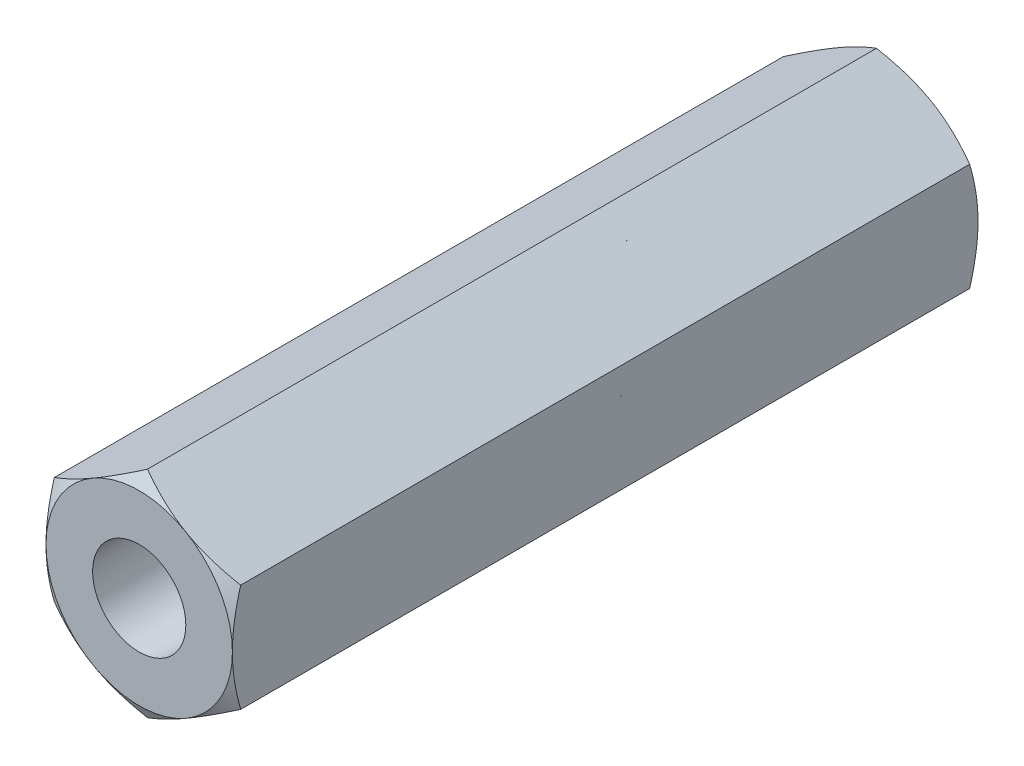
from build123d import *

# Parameters (mm, degrees)
EXTRUDE1_DEPTH          = 20
EXTRUDE1_DEPTH_BACK     = 20
SKETCH1_R               = 2.5
SKETCH8_OUTSIDE_W       = 165.094
SKETCH8_OUTSIDE_H       = 166.642
SKETCH8_OUTSIDE_R       = 5
EXTRUDE4_DEPTH          = 41.722639076
EXTRUDE4_DRAFT          = -60
MIRROR1_COPY_1_SKETCH_W = 165.094
MIRROR1_COPY_1_SKETCH_H = 166.642
MIRROR1_COPY_1_SKETCH_R = 5
MIRROR1_COPY_1_DEPTH    = 41.722639076
MIRROR1_COPY_1_DRAFT    = -60
SKETCH9_W               = 14.6
SKETCH9_H               = 2.0508


with BuildPart() as part:
    # Sketch1 → Extrude1 (new, two sides: drawn at the far end of the back side and taken through both)
    with BuildSketch(Plane.XY.offset(-EXTRUDE1_DEPTH_BACK)):
        Polygon((0, 5.773502692), (-5, 2.886751346), (-5, -2.886751346), (0, -5.773502692), (5, -2.886751346), (5, 2.886751346), align=None)
        Circle(SKETCH1_R, mode=Mode.SUBTRACT)
    extrude(amount=EXTRUDE1_DEPTH + EXTRUDE1_DEPTH_BACK)

    # Extrude3 cone 1 section (through the dimple's axis) → Extrude3 (revolve, cut)
    with BuildSketch(Plane(origin=(0, 0, -20), x_dir=(0, 1, 0), z_dir=(1, 0, 0))):
        Polygon((0, 0), (2.5508, 0), (0, 2.735398106), align=None)
    revolve(axis=Axis((0, 0, -20), (0, 0, 1)), mode=Mode.SUBTRACT)


with BuildPart() as extrude4_tool:
    # Sketch8 outside → Extrude4 (with draft: the straight prism first)
    with BuildSketch(Plane(origin=(0, 0, -20), x_dir=(-1, 0, 0), z_dir=(0, 0, -1))):
        Rectangle(SKETCH8_OUTSIDE_W, SKETCH8_OUTSIDE_H)
        Circle(SKETCH8_OUTSIDE_R, mode=Mode.SUBTRACT)
    extrude(amount=-EXTRUDE4_DEPTH)
    # Extrude4: the draft: its side faces are tilted about the plane it starts from
    extrude4_sides = [extrude4_tool.faces().sort_by_distance(p)[0] for p in [
        (0, -83.321, 0.861319538),
        (-82.547, 0, 0.861319538),
        (0, 83.321, 0.861319538),
        (82.547, 0, 0.861319538),
        (5, 0, 0.861319538),
    ]]
    draft(extrude4_sides, Plane(origin=(0, 0, -20), x_dir=(-1, 0, 0), z_dir=(0, 0, -1)), EXTRUDE4_DRAFT)


with BuildPart() as part_1:
    add(part.part)

    # Extrude4: cut by extrude4_tool
    add(extrude4_tool.part, mode=Mode.SUBTRACT)


with BuildPart() as mirror1_copy_1_tool:
    # Mirror1 copy 1 sketch → Mirror1 copy 1 (with draft: the straight prism first)
    with BuildSketch(Plane(origin=(0, 0, 20), x_dir=(-1, 0, 0), z_dir=(0, 0, 1))):
        Rectangle(MIRROR1_COPY_1_SKETCH_W, MIRROR1_COPY_1_SKETCH_H)
        Circle(MIRROR1_COPY_1_SKETCH_R, mode=Mode.SUBTRACT)
    extrude(amount=-MIRROR1_COPY_1_DEPTH)
    # Mirror1 copy 1: the draft: its side faces are tilted about the plane it starts from
    mirror1_copy_1_sides = [mirror1_copy_1_tool.faces().sort_by_distance(p)[0] for p in [
        (0, -83.321, -0.861319538),
        (-82.547, 0, -0.861319538),
        (0, 83.321, -0.861319538),
        (82.547, 0, -0.861319538),
        (5, 0, -0.861319538),
    ]]
    draft(mirror1_copy_1_sides, Plane(origin=(0, 0, 20), x_dir=(-1, 0, 0), z_dir=(0, 0, 1)), MIRROR1_COPY_1_DRAFT)


with BuildPart() as part_2:
    add(part_1.part)

    # Mirror1 copy 1: cut by mirror1_copy_1_tool
    add(mirror1_copy_1_tool.part, mode=Mode.SUBTRACT)


with BuildPart() as body_2:
    # Sketch9 → Revolve 2 (revolve)
    with BuildSketch(Plane(origin=(0, 0, 0), x_dir=(0, 0, -1), z_dir=(1, 0, 0)), mode=Mode.PRIVATE) as revolve_2_sk:
        with Locations((0, 1.0254)):
            Rectangle(SKETCH9_W, SKETCH9_H)
    revolve(revolve_2_sk.sketch.rotate(Axis((0, 0, 20), (0, 0, -1)), 270), axis=Axis((0, 0, 20), (0, 0, -1)))


solid = Compound([part_2.part, body_2.part])
